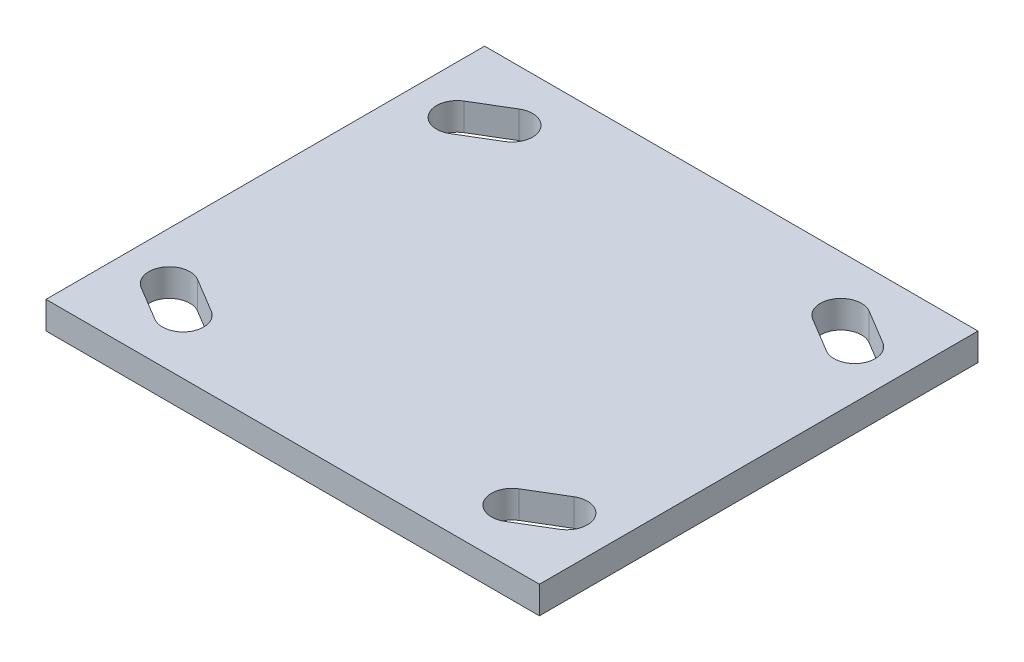
from build123d import *

# Parameters (mm, degrees)
SKETCH1_W           = 114.3
SKETCH1_H           = 6.35
BOSS_EXTRUDE1_DEPTH = 50.8
F_1_2_HOLES_DEPTH   = 7.35


with BuildPart() as part:
    # Sketch1 → Boss-Extrude1 (new body, symmetric)
    with BuildSketch(Plane.XY):
        with Locations((0, -3.175)):
            Rectangle(SKETCH1_W, SKETCH1_H)
    extrude(amount=BOSS_EXTRUDE1_DEPTH, both=True)

    # Sketch2 → 1-2 holes (cut, through all)
    with BuildSketch(Plane(origin=(0, 0, 0), x_dir=(1, 0, 0), z_dir=(0, 1, 0))):
        with BuildLine():
            Line((-35.649713965, 34.016189941), (-43.587213965, 29.253689941))
            ThreePointArc((-43.587213965, 29.253689941), (-50.121310059, 30.887213965), (-48.487786035, 37.421310059))
            Line((-48.487786035, 37.421310059), (-40.550286035, 42.183810059))
            ThreePointArc((-40.550286035, 42.183810059), (-34.016189941, 40.550286035), (-35.649713965, 34.016189941))
        make_face()
        with BuildLine():
            Line((-35.649713965, -34.016189941), (-43.587213965, -29.253689941))
            ThreePointArc((-43.587213965, -29.253689941), (-50.121310059, -30.887213965), (-48.487786035, -37.421310059))
            Line((-48.487786035, -37.421310059), (-40.550286035, -42.183810059))
            ThreePointArc((-40.550286035, -42.183810059), (-34.016189941, -40.550286035), (-35.649713965, -34.016189941))
        make_face()
        with BuildLine():
            Line((35.649713965, 34.016189941), (43.587213965, 29.253689941))
            ThreePointArc((43.587213965, 29.253689941), (50.121310059, 30.887213965), (48.487786035, 37.421310059))
            Line((48.487786035, 37.421310059), (40.550286035, 42.183810059))
            ThreePointArc((40.550286035, 42.183810059), (34.016189941, 40.550286035), (35.649713965, 34.016189941))
        make_face()
        with BuildLine():
            Line((35.649713965, -34.016189941), (43.587213965, -29.253689941))
            ThreePointArc((43.587213965, -29.253689941), (50.121310059, -30.887213965), (48.487786035, -37.421310059))
            Line((48.487786035, -37.421310059), (40.550286035, -42.183810059))
            ThreePointArc((40.550286035, -42.183810059), (34.016189941, -40.550286035), (35.649713965, -34.016189941))
        make_face()
    extrude(amount=-F_1_2_HOLES_DEPTH, mode=Mode.SUBTRACT)


solid = part.part
